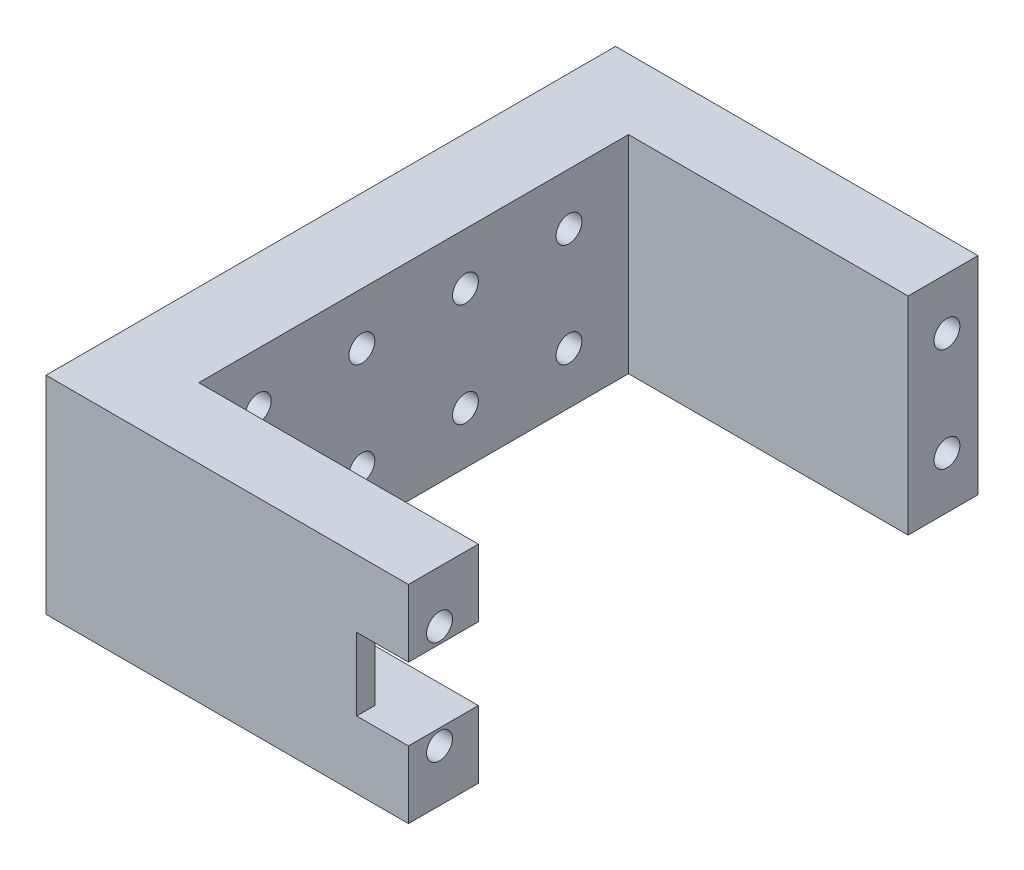
from build123d import *

# Parameters (mm, degrees)
SKETCH1_W                 = 55
SKETCH1_H                 = 20
MAIN_DEPTH                = 17.5
SKETCH3_W                 = 27
SKETCH3_H                 = 41.5
CENTRALHOLEFORSERVO_DEPTH = 21
SKETCH4_R                 = 1.25
FIXHOLESERVO_DEPTH        = 12
SKETCH5_R                 = 1.25
BOTTOMFIXHOLE_DEPTH       = 12
LPATTERN1_COUNT           = 4
LPATTERN1_PITCH           = 10
SKETCH6_W                 = 5
SKETCH6_H                 = 7
CUT_EXTRUDE4_DEPTH        = 27
SKETCH7_W                 = 1.75
SKETCH7_H                 = 7
CUT_EXTRUDE5_DEPTH        = 5


with BuildPart() as part:
    # Sketch1 → Main (new body, symmetric)
    with BuildSketch(Plane(origin=(0, 0, 0), x_dir=(0, 0, -1), z_dir=(1, 0, 0))):
        Rectangle(SKETCH1_W, SKETCH1_H)
    extrude(amount=MAIN_DEPTH, both=True)

    # Sketch3 → CentralHoleForServo (cut, through all)
    with BuildSketch(Plane(origin=(0, 10, 0), x_dir=(1, 0, 0), z_dir=(0, 1, 0))):
        with Locations((4, 0)):
            Rectangle(SKETCH3_W, SKETCH3_H)
    extrude(amount=-CENTRALHOLEFORSERVO_DEPTH, mode=Mode.SUBTRACT)

    # Sketch4 → FixHoleServo (cut)
    with BuildSketch(Plane(origin=(17.5, 0, 0), x_dir=(0, 0, -1), z_dir=(1, 0, 0))):
        with Locations((-24.5, 5)):
            Circle(SKETCH4_R)
        with Locations((-24.5, -5)):
            Circle(SKETCH4_R)
    fixholeservo = extrude(amount=-FIXHOLESERVO_DEPTH, mode=Mode.SUBTRACT)

    # FixHoleServoMirror: FixHoleServo across plane
    add(fixholeservo.mirror(Plane.XY), mode=Mode.SUBTRACT)

    # Sketch5 → BottomFixHole (cut)
    with BuildSketch(Plane.ZY.offset(17.5)):
        with Locations((15, 5)):
            Circle(SKETCH5_R)
        with Locations((15, -5)):
            Circle(SKETCH5_R)
    bottomfixhole = extrude(amount=-BOTTOMFIXHOLE_DEPTH, mode=Mode.SUBTRACT)

    # LPattern1: BottomFixHole ×4
    with Locations(*[(0, 0, -i * LPATTERN1_PITCH) for i in range(1, LPATTERN1_COUNT)]):
        add(bottomfixhole, mode=Mode.SUBTRACT)

    # Sketch6 → Cut-Extrude4 (cut)
    with BuildSketch(Plane(origin=(17.5, 0, 0), x_dir=(0, 0, -1), z_dir=(1, 0, 0))):
        with Locations((-23.25, 0)):
            Rectangle(SKETCH6_W, SKETCH6_H)
    extrude(amount=-CUT_EXTRUDE4_DEPTH, mode=Mode.SUBTRACT)

    # Sketch7 → Cut-Extrude5 (cut)
    with BuildSketch(Plane(origin=(17.5, 0, 0), x_dir=(0, 0, -1), z_dir=(1, 0, 0))):
        with Locations((-26.625, 0)):
            Rectangle(SKETCH7_W, SKETCH7_H)
    extrude(amount=-CUT_EXTRUDE5_DEPTH, mode=Mode.SUBTRACT)


solid = part.part
